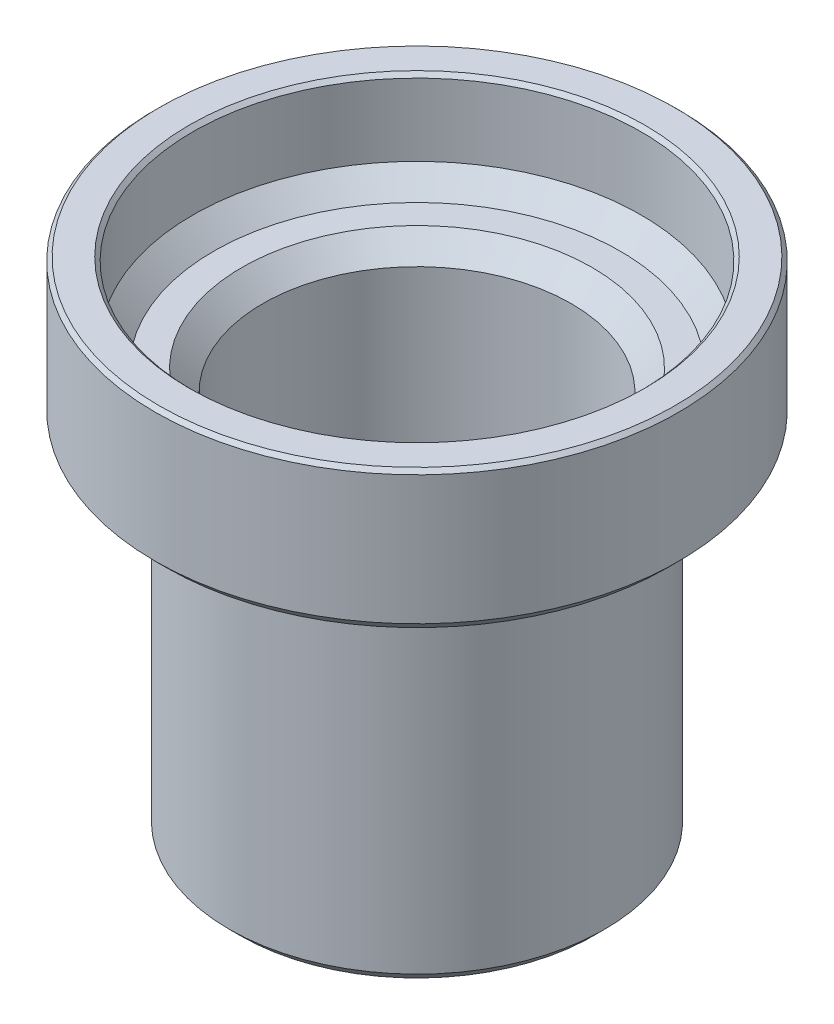
from build123d import *

# Parameters (mm, degrees)
SKETCH1_R           = 12.573
SKETCH1_R_2         = 10.31875
BOSS_EXTRUDE1_DEPTH = 26.9875
SKETCH2_R           = 17.526
SKETCH2_R_2         = 10.31875
BOSS_EXTRUDE2_DEPTH = 3.175
SKETCH3_R           = 17.526
SKETCH3_R_2         = 15
BOSS_EXTRUDE3_DEPTH = 6.477
CHAMFER1_SIZE       = 0.762
CHAMFER3_SIZE       = 0.254
CHAMFER4_SIZE       = 0.254
CHAMFER5_SIZE       = 1.397
CHAMFER6_SIZE       = 1.397


with BuildPart() as part:
    # Sketch1 → Boss-Extrude1 (new body)
    with BuildSketch(Plane(origin=(0, 0, 0), x_dir=(1, 0, 0), z_dir=(0, 1, 0))):
        Circle(SKETCH1_R)
        Circle(SKETCH1_R_2, mode=Mode.SUBTRACT)
    extrude(amount=BOSS_EXTRUDE1_DEPTH)

    # Sketch2 → Boss-Extrude2 (add)
    with BuildSketch(Plane(origin=(0, 26.9875, 0), x_dir=(1, 0, 0), z_dir=(0, 1, 0))):
        Circle(SKETCH2_R)
        Circle(SKETCH2_R_2, mode=Mode.SUBTRACT)
    extrude(amount=-BOSS_EXTRUDE2_DEPTH)

    # Sketch3 → Boss-Extrude3 (add)
    with BuildSketch(Plane(origin=(0, 26.9875, 0), x_dir=(1, 0, 0), z_dir=(0, 1, 0))):
        Circle(SKETCH3_R)
        Circle(SKETCH3_R_2, mode=Mode.SUBTRACT)
    extrude(amount=BOSS_EXTRUDE3_DEPTH)

    # Chamfer1
    chamfer1_edges = [part.edges().sort_by_distance(p)[0] for p in [
        (-17.526, 23.8125, 0),
        (-12.573, 0, 0),
    ]]
    chamfer(chamfer1_edges, length=CHAMFER1_SIZE)

    # Chamfer3
    chamfer3_edges = [part.edges().sort_by_distance(p)[0] for p in [
        (-17.526, 33.4645, 0),
    ]]
    chamfer(chamfer3_edges, length=CHAMFER3_SIZE)

    # Chamfer4
    chamfer4_edges = [part.edges().sort_by_distance(p)[0] for p in [
        (-15, 33.4645, 0),
    ]]
    chamfer(chamfer4_edges, length=CHAMFER4_SIZE)

    # Chamfer5
    chamfer5_edges = [part.edges().sort_by_distance(p)[0] for p in [
        (-15, 26.9875, 0),
    ]]
    chamfer(chamfer5_edges, length=CHAMFER5_SIZE)

    # Chamfer6
    chamfer6_edges = [part.edges().sort_by_distance(p)[0] for p in [
        (-10.31875, 26.9875, 0),
    ]]
    chamfer(chamfer6_edges, length=CHAMFER6_SIZE)


solid = part.part
